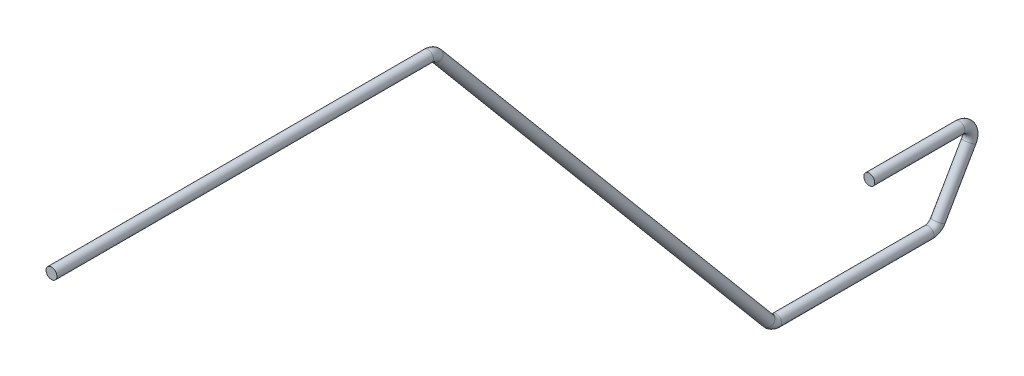
from build123d import *

# Parameters (mm, degrees)
SWEEP1_PROFILE_R = 0.254


with BuildPart() as part:
    # Sweep1: sweep along a path in Sketch1
    with BuildLine(Plane(origin=(0, 0, 0), x_dir=(0, 0, -1), z_dir=(1, 0, 0))) as sweep1_path:
        Line((0, 0), (17.54311571, 0))
        ThreePointArc((17.54311571, 0), (17.757805787, -0.047595644), (17.932266287, -0.181463894))
        Line((17.932266287, -0.181463894), (33.38103842, -18.592593586))
        ThreePointArc((33.38103842, -18.592593586), (33.55549892, -18.726461836), (33.770188997, -18.77405748))
        Line((33.770188997, -18.77405748), (40.86001077, -18.77405748))
        ThreePointArc((40.86001077, -18.77405748), (41.11401077, -18.705998385), (41.299951675, -18.52005748))
        Line((41.299951675, -18.52005748), (42.740059095, -16.025718261))
        ThreePointArc((42.740059095, -16.025718261), (42.740059095, -15.517718261), (42.30011819, -15.263718261))
        Line((42.30011819, -15.263718261), (38.1, -15.263718261))
    # Sweep1 profile (on start of the path) → Sweep1 (sweep)
    with BuildSketch(Plane(origin=(0, 0, 0), x_dir=(-1, 0, 0), z_dir=(0, 0, -1))):
        Circle(SWEEP1_PROFILE_R)
    sweep(path=sweep1_path.line)


solid = part.part
